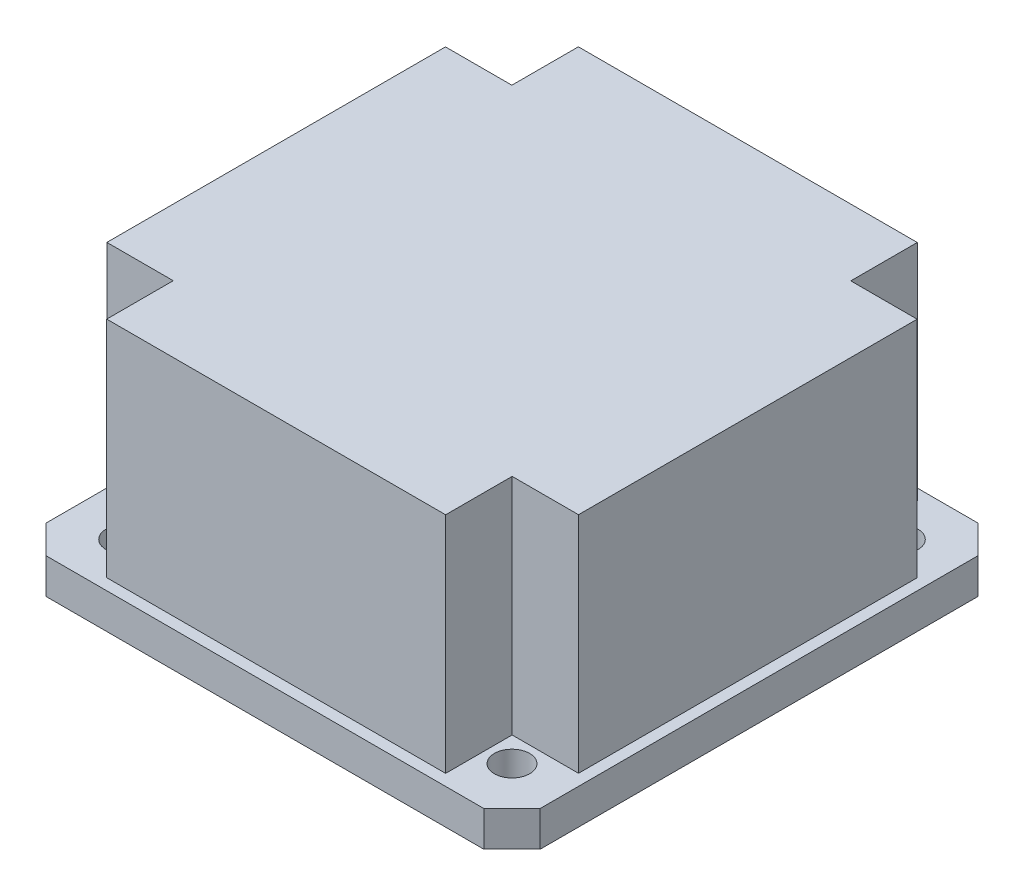
from build123d import *

# Parameters (mm, degrees)
SKETCH2_W                                  = 44.45
SKETCH2_H                                  = 44.45
BOSS_EXTRUDE1_DEPTH                        = 3.175
CHAMFER1_SIZE                              = 2.54
SKETCH3_R                                  = 1.5875
CUT_EXTRUDE1_DEPTH                         = 4.175
MIRROR2_COPY_1_SKETCH_R                    = 1.5875
MIRROR2_COPY_1_DEPTH                       = 4.175
SKETCH4_W                                  = 42.418
SKETCH4_H                                  = 42.418
BOSS_EXTRUDE2_DEPTH                        = 20.1422
SKETCH5_W                                  = 5.969
SKETCH5_H                                  = 5.9817
CUT_EXTRUDE2_DEPTH                         = 20.1422
MIRROR3_AT_THE_SECOND_PLANE_COPY_1_SKETC_W = 5.969
MIRROR3_AT_THE_SECOND_PLANE_COPY_1_SKETC_H = 5.9817
MIRROR3_AT_THE_SECOND_PLANE_COPY_1_DEPTH   = 20.1422


with BuildPart() as part:
    # Sketch2 → Boss-Extrude1 (new body)
    with BuildSketch(Plane(origin=(0, 0, 0), x_dir=(1, 0, 0), z_dir=(0, 1, 0))):
        Rectangle(SKETCH2_W, SKETCH2_H)
    extrude(amount=BOSS_EXTRUDE1_DEPTH)

    # Chamfer1
    chamfer1_edges = [part.edges().sort_by_distance(p)[0] for p in [
        (22.225, 1.5875, 22.225),
        (-22.225, 1.5875, 22.225),
        (-22.225, 1.5875, -22.225),
        (22.225, 1.5875, -22.225),
    ]]
    chamfer(chamfer1_edges, length=CHAMFER1_SIZE)

    # Sketch3 → Cut-Extrude1 (cut, through all)
    with BuildSketch(Plane(origin=(0, 3.175, 0), x_dir=(1, 0, 0), z_dir=(0, 1, 0))):
        with Locations((-17.4625, 17.4625)):
            Circle(SKETCH3_R)
    cut_extrude1 = extrude(amount=-CUT_EXTRUDE1_DEPTH, mode=Mode.SUBTRACT)

    # Mirror1: Cut-Extrude1 across plane
    add(cut_extrude1.mirror(Plane(origin=(0, 0, 0), x_dir=(0, 0, 1), z_dir=(1, 0, 0))), mode=Mode.SUBTRACT)

    # Mirror2: Cut-Extrude1 across plane
    add(cut_extrude1.mirror(Plane.XY), mode=Mode.SUBTRACT)

    # Mirror2 copy 1 sketch → Mirror2 copy 1 (cut, through all)
    with BuildSketch(Plane(origin=(0, 3.175, 0), x_dir=(-1, 0, 0), z_dir=(0, 1, 0))):
        with Locations((-17.4625, 17.4625)):
            Circle(MIRROR2_COPY_1_SKETCH_R)
    extrude(amount=-MIRROR2_COPY_1_DEPTH, mode=Mode.SUBTRACT)

    # Sketch4 → Boss-Extrude2 (add)
    with BuildSketch(Plane(origin=(0, 3.175, 0), x_dir=(1, 0, 0), z_dir=(0, 1, 0))):
        Rectangle(SKETCH4_W, SKETCH4_H)
    extrude(amount=BOSS_EXTRUDE2_DEPTH)

    # Sketch5 → Cut-Extrude2 (cut)
    with BuildSketch(Plane(origin=(0, 23.3172, 0), x_dir=(1, 0, 0), z_dir=(0, 1, 0))):
        with Locations((-18.2245, 18.21815)):
            Rectangle(SKETCH5_W, SKETCH5_H)
    cut_extrude2 = extrude(amount=-CUT_EXTRUDE2_DEPTH, mode=Mode.SUBTRACT)

    # Mirror3: Cut-Extrude2 across plane
    add(cut_extrude2.mirror(Plane(origin=(0, 0, 0), x_dir=(0, 0, 1), z_dir=(1, 0, 0))), mode=Mode.SUBTRACT)

    # Mirror3 at the second plane: Cut-Extrude2 across plane
    add(cut_extrude2.mirror(Plane.XY), mode=Mode.SUBTRACT)

    # Mirror3 at the second plane copy 1 sketc → Mirror3 at the second plane copy 1 (cut)
    with BuildSketch(Plane(origin=(0, 23.3172, 0), x_dir=(-1, 0, 0), z_dir=(0, 1, 0))):
        with Locations((-18.2245, 18.21815)):
            Rectangle(MIRROR3_AT_THE_SECOND_PLANE_COPY_1_SKETC_W, MIRROR3_AT_THE_SECOND_PLANE_COPY_1_SKETC_H)
    extrude(amount=-MIRROR3_AT_THE_SECOND_PLANE_COPY_1_DEPTH, mode=Mode.SUBTRACT)


solid = part.part
